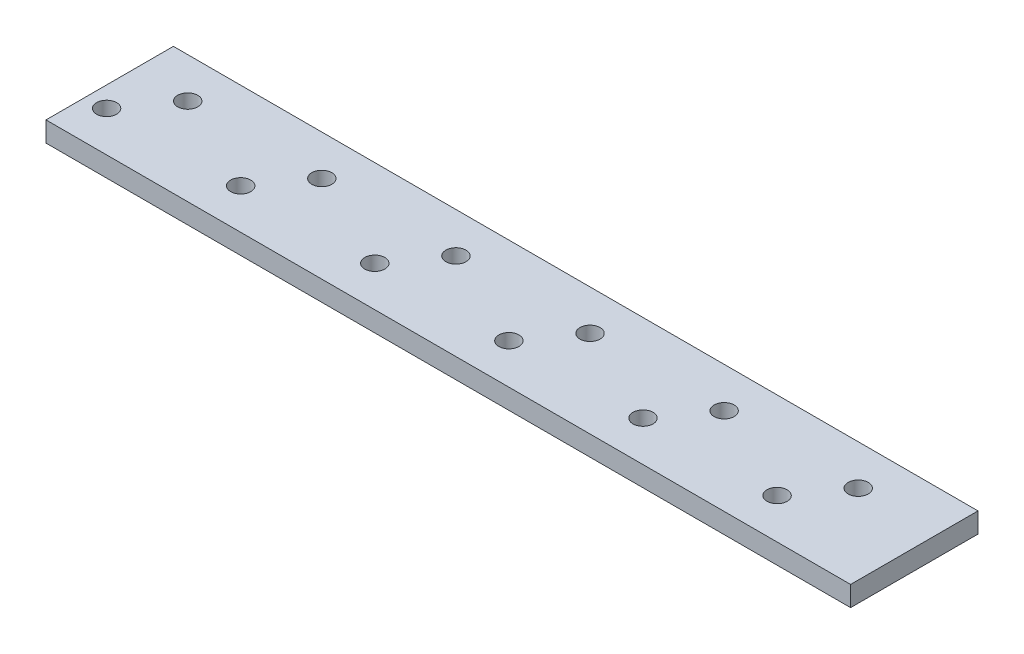
from build123d import *

# Parameters (mm, degrees)
SKETCH_1_W          = 120
SKETCH_1_H          = 19
EXTRUDE_1_DEPTH     = 3
SKETCH_2_R          = 1.5
CUT_EXTRUDE_1_DEPTH = 3


with BuildPart() as part:
    # Эскиз1 → Бобышка-Вытянуть1 (new body)
    with BuildSketch(Plane(origin=(0, 0, 0), x_dir=(1, 0, 0), z_dir=(0, 1, 0))):
        Rectangle(SKETCH_1_W, SKETCH_1_H)
    extrude(amount=EXTRUDE_1_DEPTH)

    # Эскиз2 → Вырез-Вытянуть1 (cut)
    with BuildSketch(Plane(origin=(0, 3, 0), x_dir=(1, 0, 0), z_dir=(0, 1, 0))):
        with Locations((-51.862444671, 3.5)):
            Circle(SKETCH_2_R)
        with Locations((-56.963668737, -3.5)):
            Circle(SKETCH_2_R)
        with Locations((-31.862444671, 3.5)):
            Circle(SKETCH_2_R)
        with Locations((-36.963668737, -3.5)):
            Circle(SKETCH_2_R)
        with Locations((-11.862444671, 3.5)):
            Circle(SKETCH_2_R)
        with Locations((-16.963668737, -3.5)):
            Circle(SKETCH_2_R)
        with Locations((8.137555329, 3.5)):
            Circle(SKETCH_2_R)
        with Locations((3.036331263, -3.5)):
            Circle(SKETCH_2_R)
        with Locations((28.137555329, 3.5)):
            Circle(SKETCH_2_R)
        with Locations((23.036331263, -3.5)):
            Circle(SKETCH_2_R)
        with Locations((48.137555329, 3.5)):
            Circle(SKETCH_2_R)
        with Locations((43.036331263, -3.5)):
            Circle(SKETCH_2_R)
    extrude(amount=-CUT_EXTRUDE_1_DEPTH, mode=Mode.SUBTRACT)


solid = part.part
